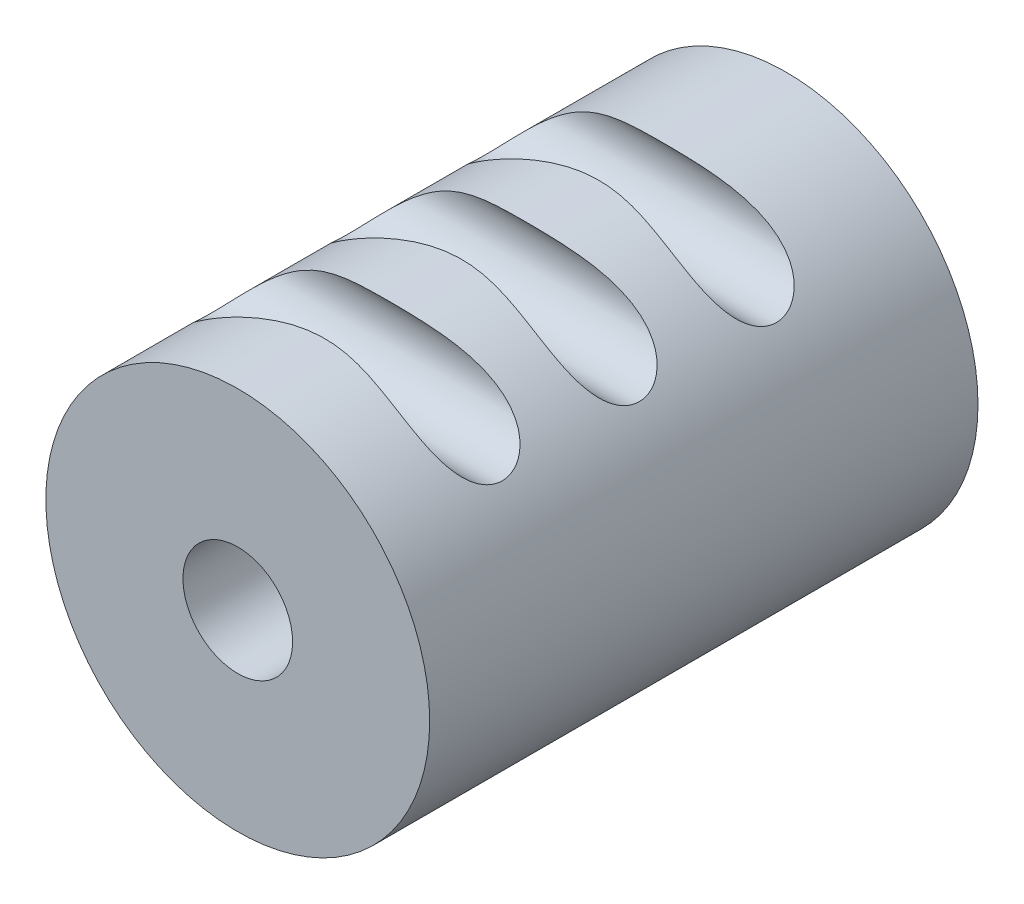
from build123d import *

# Parameters (mm, degrees)
SKETCH1_R               = 14
SKETCH1_R_2             = 4
EXTRUDE_THIN1_DEPTH     = 40
SKETCH2_R               = 3
CUT_EXTRUDE1_DEPTH      = 15
CUT_EXTRUDE1_DEPTH_BACK = 15


with BuildPart() as part:
    # Sketch1 → Extrude-Thin1 (new body)
    with BuildSketch(Plane.XY):
        Circle(SKETCH1_R)
        Circle(SKETCH1_R_2, mode=Mode.SUBTRACT)
    extrude(amount=EXTRUDE_THIN1_DEPTH)

    # Sketch2 → Cut-Extrude1 (cut, two sides)
    with BuildSketch(Plane(origin=(0, 0, 0), x_dir=(0, 0, -1), z_dir=(1, 0, 0))) as cut_extrude1_sk:
        with Locations((-31.312329447, 12.13670973)):
            Circle(SKETCH2_R)
        with Locations((-21.312329447, 12.13670973)):
            Circle(SKETCH2_R)
        with Locations((-11.312329447, 12.13670973)):
            Circle(SKETCH2_R)
        with Locations((-21.312329447, -12.86329027)):
            Circle(SKETCH2_R)
        with Locations((-11.312329447, -12.86329027)):
            Circle(SKETCH2_R)
        with Locations((-31.312329447, -12.86329027)):
            Circle(SKETCH2_R)
    extrude(amount=CUT_EXTRUDE1_DEPTH, mode=Mode.SUBTRACT)
    extrude(cut_extrude1_sk.sketch, amount=-CUT_EXTRUDE1_DEPTH_BACK, mode=Mode.SUBTRACT)


solid = part.part
